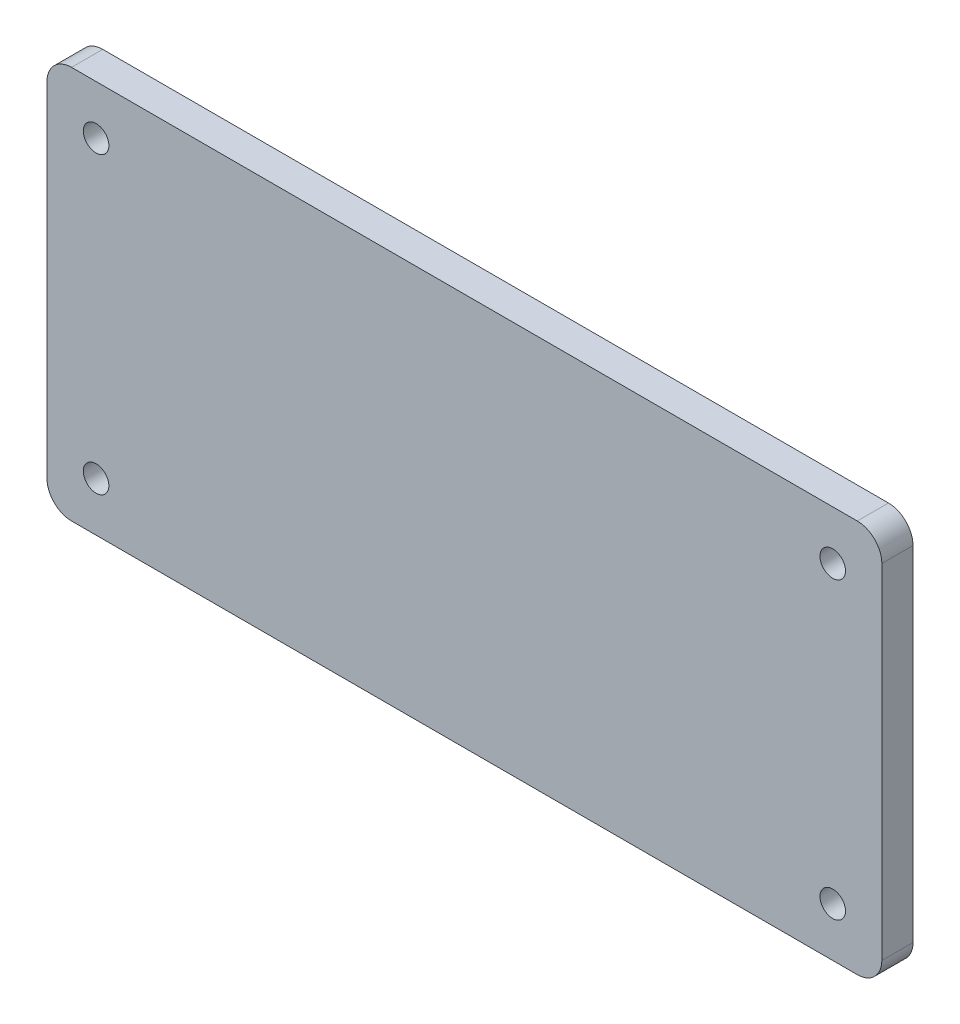
from build123d import *

# Parameters (mm, degrees)
SKETCH1_R           = 2.6
BOSS_EXTRUDE1_DEPTH = 6.35


with BuildPart() as part:
    # Sketch1 → Boss-Extrude1 (new body)
    with BuildSketch(Plane.XY):
        with BuildLine():
            Line((80, -40), (-80, -40))
            ThreePointArc((-80, -40), (-83.535533906, -38.535533906), (-85, -35))
            Line((-85, -35), (-85, 35))
            ThreePointArc((-85, 35), (-83.535533906, 38.535533906), (-80, 40))
            Line((-80, 40), (80, 40))
            ThreePointArc((80, 40), (83.535533906, 38.535533906), (85, 35))
            Line((85, 35), (85, -35))
            ThreePointArc((85, -35), (83.535533906, -38.535533906), (80, -40))
        make_face()
        with Locations((-75, 30)):
            Circle(SKETCH1_R, mode=Mode.SUBTRACT)
        with Locations((75, 30)):
            Circle(SKETCH1_R, mode=Mode.SUBTRACT)
        with Locations((75, -30)):
            Circle(SKETCH1_R, mode=Mode.SUBTRACT)
        with Locations((-75, -30)):
            Circle(SKETCH1_R, mode=Mode.SUBTRACT)
    extrude(amount=BOSS_EXTRUDE1_DEPTH)


solid = part.part
